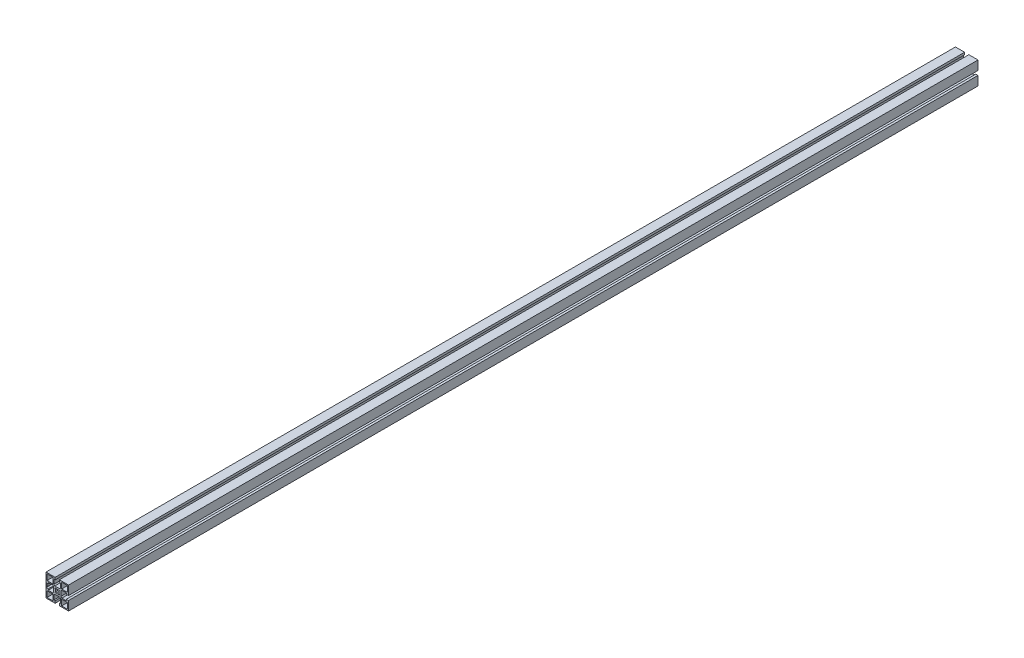
from build123d import *

# Parameters (mm, degrees)
SKETCH1_W           = 11.699975178
SKETCH1_H           = 11.699996949
SKETCH1_W_2         = 11.699990436
SKETCH1_H_2         = 11.699981689
SKETCH1_W_3         = 11.699990437
SKETCH1_H_3         = 11.699975177
SKETCH1_W_4         = 11.699981689
SKETCH1_H_4         = 11.699990436
BOSS_EXTRUDE1_DEPTH = 1816.1
CUT_EXTRUDE1_REACH  = 1818.379


with BuildPart() as part:
    # Sketch1 → Boss-Extrude1 (new body)
    with BuildSketch(Plane.XY):
        Polygon((22.500515052, 22.499297556), (-22.499484399, 22.499298105), (-22.499484948, -22.500701346), (-4.249491942, -22.500701568), (-4.249491942, -22.200733242), (-4.24949208, -18.000719999), (-6.799479919, -18.000719999), (-6.799480207, -9.200732353), (-4.799480391, -7.200732362), (4.800525817, -7.200732047), (6.8005258, -9.200731855), (6.800526088, -18.000720263), (4.250507877, -18.000720263), (4.250508015, -22.200733153), (4.250508015, -22.500701672), (22.500514502, -22.500701895), (22.500514725, -4.250714302), (22.200520351, -4.250714302), (18.000507108, -4.25071444), (18.000507108, -6.800702279), (9.200519462, -6.800702567), (7.200519471, -4.800702751), (7.200519156, 4.799303458), (9.200518964, 6.79930344), (18.000507424, 6.799303729), (18.000507424, 4.249285514), (22.200520261, 4.249285652), (22.500514829, 4.249285652), align=None)
        with BuildLine():
            Line((-4.249491247, 17.999291576), (-4.249490956, 22.199304807))
            Line((-4.249490956, 22.199304807), (-3.949472548, 22.199304807))
            Line((-3.949472548, 22.199304807), (-3.481695222, 21.73152644))
            ThreePointArc((-3.481695222, 21.73152644), (-2.670636178, 21.189593132), (-1.713926324, 20.999291428))
            Line((-1.713926324, 20.999291428), (1.714975167, 20.999291428))
            ThreePointArc((1.714975167, 20.999291428), (2.671722509, 21.189608628), (3.482801459, 21.731583767))
            Line((3.482801459, 21.731583767), (3.950490798, 22.199304487))
            Line((3.950490798, 22.199304487), (4.250509108, 22.199304487))
            Line((4.250509108, 22.199304487), (4.250508817, 17.999291575))
            Line((4.250508817, 17.999291575), (6.800527063, 17.999291575))
            Line((6.800527063, 17.999291575), (6.800526453, 9.199302988))
            Line((6.800526453, 9.199302988), (4.800526064, 7.199302969))
            Line((4.800526064, 7.199302969), (-4.799479817, 7.199303635))
            Line((-4.799479817, 7.199303635), (-6.799479854, 9.199304042))
            Line((-6.799479854, 9.199304042), (-6.799479244, 17.999291576))
            Line((-6.799479244, 17.999291576), (-4.249491247, 17.999291576))
        make_face(mode=Mode.SUBTRACT)
        with BuildLine():
            Line((-17.99949762, -4.250714253), (-22.199510799, -4.250714391))
            Line((-22.199510799, -4.250714391), (-22.199510799, -3.950696126))
            Line((-22.199510799, -3.950696126), (-21.731790056, -3.48300681))
            ThreePointArc((-21.731790056, -3.48300681), (-21.189814855, -2.671927844), (-20.999497617, -1.71518046))
            Line((-20.999497617, -1.71518046), (-20.999497617, 1.713721031))
            ThreePointArc((-20.999497617, 1.713721031), (-21.189799286, 2.670430863), (-21.731732544, 3.481489907))
            Line((-21.731732544, 3.481489907), (-22.199510888, 3.949267256))
            Line((-22.199510888, 3.949267256), (-22.199510888, 4.249285566))
            Line((-22.199510888, 4.249285566), (-17.999497356, 4.249285704))
            Line((-17.999497356, 4.249285704), (-17.999497356, 6.79927354))
            Line((-17.999497356, 6.79927354), (-9.199509947, 6.799273828))
            Line((-9.199509947, 6.799273828), (-7.199509956, 4.799274012))
            Line((-7.199509956, 4.799274012), (-7.199509641, -4.800732197))
            Line((-7.199509641, -4.800732197), (-9.199509449, -6.800732179))
            Line((-9.199509449, -6.800732179), (-17.99949762, -6.800732468))
            Line((-17.99949762, -6.800732468), (-17.99949762, -4.250714253))
        make_face(mode=Mode.SUBTRACT)
        with Locations((-14.649542346, -14.650709384)):
            Rectangle(SKETCH1_W, SKETCH1_H, mode=Mode.SUBTRACT)
        with Locations((14.65050626, -14.650767962)):
            Rectangle(SKETCH1_W_2, SKETCH1_H_2, mode=Mode.SUBTRACT)
        with BuildLine():
            Line((-3.181457266, -4.596908447), (-4.595670829, -3.182694885))
            Line((-4.595670829, -3.182694885), (-3.26221457, -1.849238626))
            ThreePointArc((-3.26221457, -1.849238626), (-3.749476751, -0.00071437), (-3.26221457, 1.847809887))
            Line((-3.26221457, 1.847809887), (-4.595670829, 3.181266146))
            Line((-4.595670829, 3.181266146), (-3.181457266, 4.595479708))
            Line((-3.181457266, 4.595479708), (-1.848001007, 3.262023449))
            ThreePointArc((-1.848001007, 3.262023449), (0.000523249, 3.74928563), (1.849047505, 3.262023449))
            Line((1.849047505, 3.262023449), (3.182503764, 4.595479708))
            Line((3.182503764, 4.595479708), (4.596717327, 3.181266146))
            Line((4.596717327, 3.181266146), (3.263261068, 1.847809887))
            ThreePointArc((3.263261068, 1.847809887), (3.750523249, -0.00071437), (3.263261068, -1.849238626))
            Line((3.263261068, -1.849238626), (4.596717327, -3.182694885))
            Line((4.596717327, -3.182694885), (3.182503764, -4.596908447))
            Line((3.182503764, -4.596908447), (1.849047505, -3.263452188))
            ThreePointArc((1.849047505, -3.263452188), (0.000523249, -3.75071437), (-1.848001007, -3.263452188))
            Line((-1.848001007, -3.263452188), (-3.181457266, -4.596908447))
        make_face(mode=Mode.SUBTRACT)
        with Locations((-14.64949028, 14.649335967)):
            Rectangle(SKETCH1_W_3, SKETCH1_H_3, mode=Mode.SUBTRACT)
        with Locations((14.650561583, 14.6492839)):
            Rectangle(SKETCH1_W_4, SKETCH1_H_4, mode=Mode.SUBTRACT)
    extrude(amount=BOSS_EXTRUDE1_DEPTH)

    # Sketch1_4 → Cut-Extrude1 (cut, up to next)
    with BuildSketch(Plane.XY, mode=Mode.PRIVATE) as cut_extrude1_sk1:
        with BuildLine():
            Line((-4.249490956, 22.499297883), (-4.249490956, 22.199304807))
            Line((-4.249490956, 22.199304807), (-3.949472548, 22.199304807))
            Line((-3.949472548, 22.199304807), (-3.481695222, 21.73152644))
            ThreePointArc((-3.481695222, 21.73152644), (-2.670636178, 21.189593132), (-1.713926324, 20.999291428))
            Line((-1.713926324, 20.999291428), (1.714975167, 20.999291428))
            ThreePointArc((1.714975167, 20.999291428), (2.671722509, 21.189608628), (3.482801459, 21.731583767))
            Line((3.482801459, 21.731583767), (3.950490798, 22.199304487))
            Line((3.950490798, 22.199304487), (4.250509108, 22.199304487))
            Line((4.250509108, 22.199304487), (4.250509108, 22.499297779))
            Line((4.250509108, 22.499297779), (-4.249490956, 22.499297883))
        make_face()
    cut_extrude1_tool1 = extrude(cut_extrude1_sk1.sketch, amount=CUT_EXTRUDE1_REACH, mode=Mode.PRIVATE) & part.part
    add(cut_extrude1_tool1.solids().sort_by_distance((0.000518, 21.824215, 0))[0], mode=Mode.SUBTRACT)


solid = part.part
